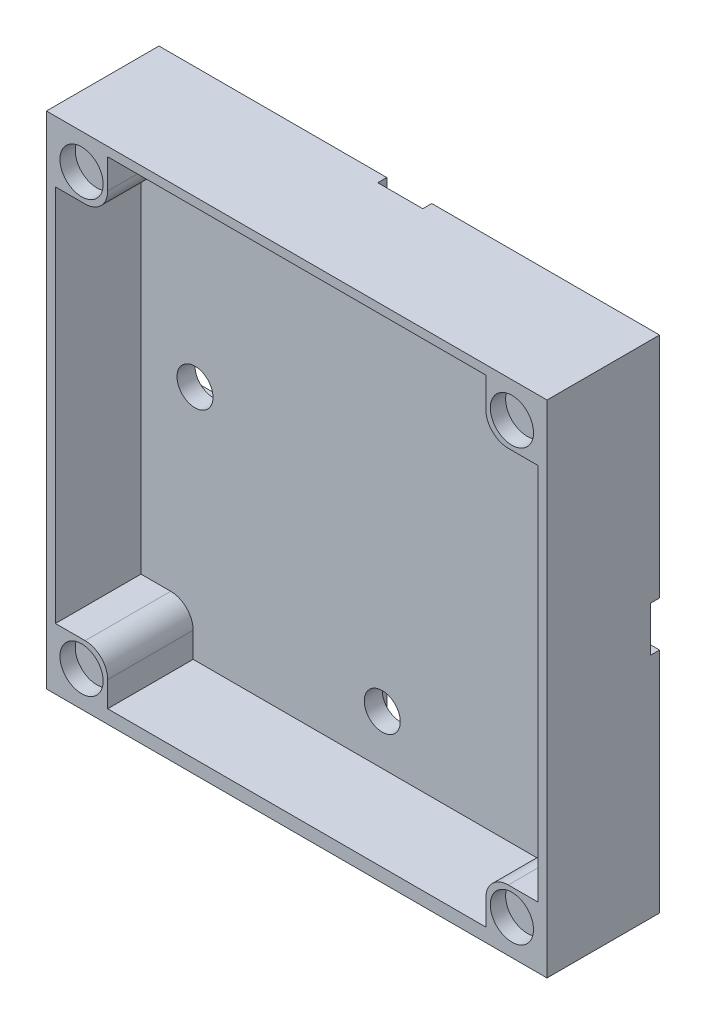
from build123d import *

# Parameters (mm, degrees)
SKICA1_W                 = 55.6
SKICA1_H                 = 55.6
P_IDAT_VYSUNUT_M2_DEPTH  = 3
SKICA5_W                 = 5
SKICA5_H                 = 55.6
SKICA5_W_2               = 55.6
SKICA5_H_2               = 5
ODEBRAT_VYSUNUT_M3_DEPTH = 1
SKICA14_W                = 53.6
SKICA14_H                = 1.5
P_IDAT_VYSUNUT_M9_DEPTH  = 9.5
SKICA17_R                = 2
ODEBRAT_VYSUNUT_M8_DEPTH = 4
SKICA19_W                = 6.8
SKICA19_H                = 6.8
P_IDAT_VYSUNUT_M10_DEPTH = 12.5
SKICA20_R                = 2.4
ODEBRAT_VYSUNUT_M9_DEPTH = 1.7
ZAOBLIT1_R               = 2.5


with BuildPart() as part:
    # Skica1 → Přidat vysunutím2 (new body)
    with BuildSketch(Plane.XY):
        Rectangle(SKICA1_W, SKICA1_H)
    extrude(amount=P_IDAT_VYSUNUT_M2_DEPTH)

    # Skica5 → Odebrat vysunutím3 (cut)
    with BuildSketch(Plane(origin=(0, 0, 0), x_dir=(-1, 0, 0), z_dir=(0, 0, -1))):
        Rectangle(SKICA5_W, SKICA5_H)
        Rectangle(SKICA5_W_2, SKICA5_H_2)
    extrude(amount=-ODEBRAT_VYSUNUT_M3_DEPTH, mode=Mode.SUBTRACT)

    # Skica14 → Přidat vysunutím9 (add)
    with BuildSketch(Plane.XY.offset(3)):
        Polygon((27.8, 27.8), (-27.8, 27.8), (-27.8, -27.8), (-26.8, -27.8), (-26.8, -26.8), (-26.8, -26.3), (-26.8, 26.8), (26.8, 26.8), (26.8, -26.3), (26.8, -27.8), (27.8, -27.8), align=None)
        with Locations((0, -27.05)):
            Rectangle(SKICA14_W, SKICA14_H)
    extrude(amount=P_IDAT_VYSUNUT_M9_DEPTH)

    # Skica17 → Odebrat vysunutím8 (cut)
    with BuildSketch(Plane(origin=(0, 0, 1), x_dir=(-1, 0, 0), z_dir=(0, 0, -1))):
        with Locations((20.8, 0)):
            Circle(SKICA17_R)
        with Locations((-20.8, 0)):
            Circle(SKICA17_R)
        with Locations((0, 20.8)):
            Circle(SKICA17_R)
        with Locations((0, -20.8)):
            Circle(SKICA17_R)
    extrude(amount=-ODEBRAT_VYSUNUT_M8_DEPTH, mode=Mode.SUBTRACT)

    # Skica19 → Přidat vysunutím10 (add)
    with BuildSketch(Plane(origin=(0, 0, 0), x_dir=(-1, 0, 0), z_dir=(0, 0, -1))):
        with Locations((-24.4, 24.4)):
            Rectangle(SKICA19_W, SKICA19_H)
        with Locations((24.4, 24.4)):
            Rectangle(SKICA19_W, SKICA19_H)
        with Locations((-24.4, -24.4)):
            Rectangle(SKICA19_W, SKICA19_H)
        with Locations((24.4, -24.4)):
            Rectangle(SKICA19_W, SKICA19_H)
    extrude(amount=-P_IDAT_VYSUNUT_M10_DEPTH)

    # Skica20 → Odebrat vysunutím9 (cut)
    with BuildSketch(Plane.XY.offset(12.5)):
        with Locations((-23.9, -23.9)):
            Circle(SKICA20_R)
        with Locations((-23.9, 23.9)):
            Circle(SKICA20_R)
        with Locations((23.900280565, 23.9)):
            Circle(SKICA20_R)
        with Locations((23.900280565, -23.9)):
            Circle(SKICA20_R)
    extrude(amount=-ODEBRAT_VYSUNUT_M9_DEPTH, mode=Mode.SUBTRACT)

    # Zaoblit1
    zaoblit1_edges = [part.edges().sort_by_distance(p)[0] for p in [
        (21, 21, 7.75),
        (-21, 21, 7.75),
        (21, -21, 7.75),
        (-21, -21, 7.75),
    ]]
    fillet(zaoblit1_edges, radius=ZAOBLIT1_R)


solid = part.part
